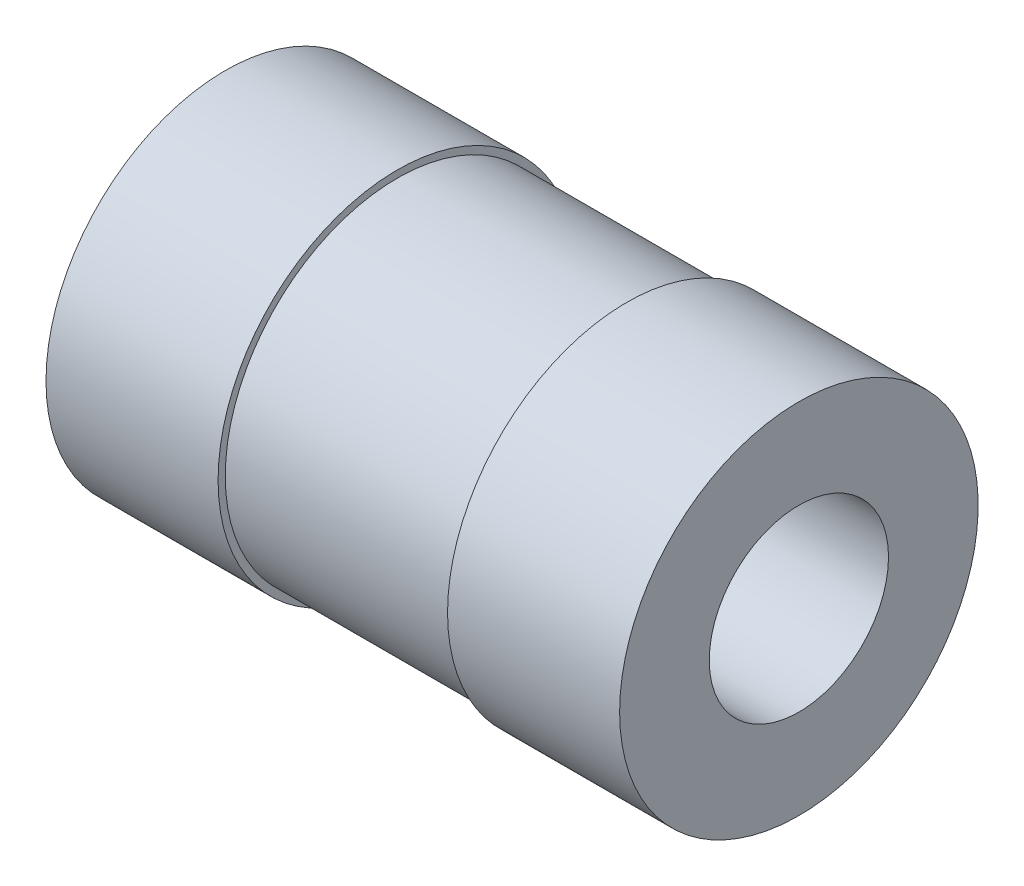
from build123d import *


with BuildPart() as part:
    # 草图1 → 旋转1 (revolve)
    with BuildSketch(Plane.XY):
        Polygon((-4, 1.25), (4, 1.25), (4, 2.5), (1.6, 2.5), (1.6, 2.4), (-1.6, 2.4), (-1.6, 2.5), (-4, 2.5), align=None)
    revolve(axis=Axis((-2.022624434, 0, 0), (1, 0, 0)))


solid = part.part
